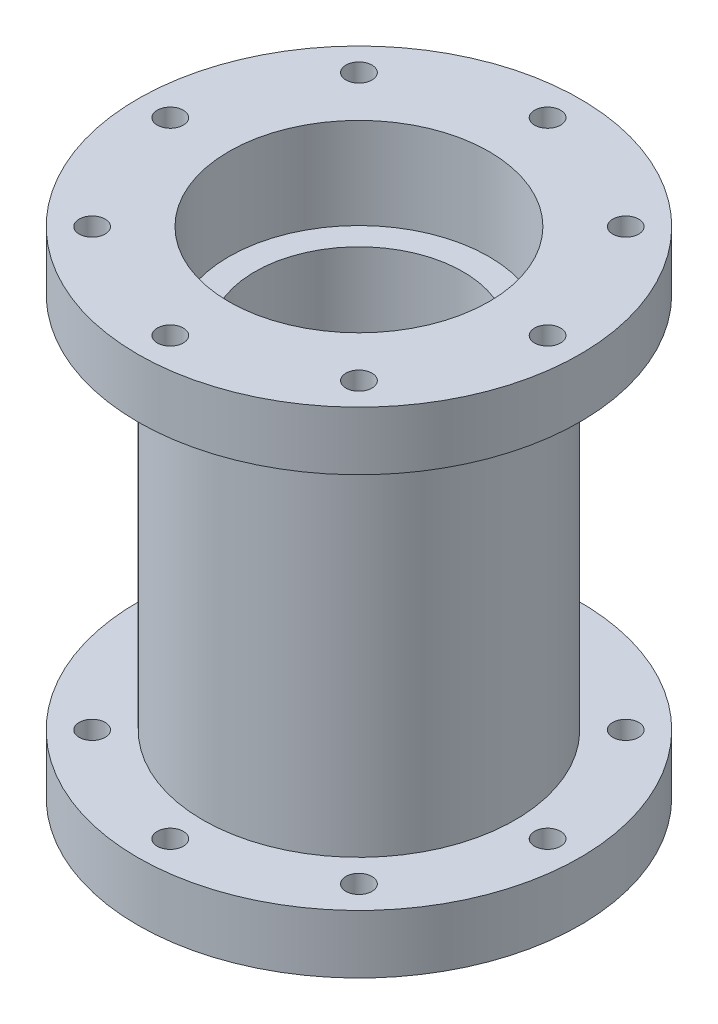
from build123d import *

# Parameters (mm, degrees)
SKETCH4_R           = 34
SKETCH4_R_2         = 24
SKETCH4_R_3         = 2
BOSS_EXTRUDE1_DEPTH = 9


with BuildPart() as part:
    # Sketch1 → Revolve1 (revolve)
    with BuildSketch(Plane.XY):
        Polygon((-12, 8), (-12, -8), (-16, -8), (-16, -24), (-20, -24), (-20, -38), (-24, -38), (-24, 38), (-20, 38), (-20, 24), (-16, 24), (-16, 8), align=None)
    revolve(axis=Axis((0, 75.096781517, 0), (0, -1, 0)))

    # Sketch4 → Boss-Extrude1 (add)
    with BuildSketch(Plane(origin=(0, 38, 0), x_dir=(1, 0, 0), z_dir=(0, 1, 0))):
        Circle(SKETCH4_R)
        Circle(SKETCH4_R_2, mode=Mode.SUBTRACT)
        with Locations((0, 29)):
            Circle(SKETCH4_R_3, mode=Mode.SUBTRACT)
        with Locations((20.506096654, 20.506096654)):
            Circle(SKETCH4_R_3, mode=Mode.SUBTRACT)
        with Locations((29, 0)):
            Circle(SKETCH4_R_3, mode=Mode.SUBTRACT)
        with Locations((20.506096654, -20.506096654)):
            Circle(SKETCH4_R_3, mode=Mode.SUBTRACT)
        with Locations((0, -29)):
            Circle(SKETCH4_R_3, mode=Mode.SUBTRACT)
        with Locations((-20.506096654, -20.506096654)):
            Circle(SKETCH4_R_3, mode=Mode.SUBTRACT)
        with Locations((-29, 0)):
            Circle(SKETCH4_R_3, mode=Mode.SUBTRACT)
        with Locations((-20.506096654, 20.506096654)):
            Circle(SKETCH4_R_3, mode=Mode.SUBTRACT)
    boss_extrude1 = extrude(amount=-BOSS_EXTRUDE1_DEPTH)

    # Mirror1: Boss-Extrude1 across plane
    add(boss_extrude1.mirror(Plane.ZX))


solid = part.part
